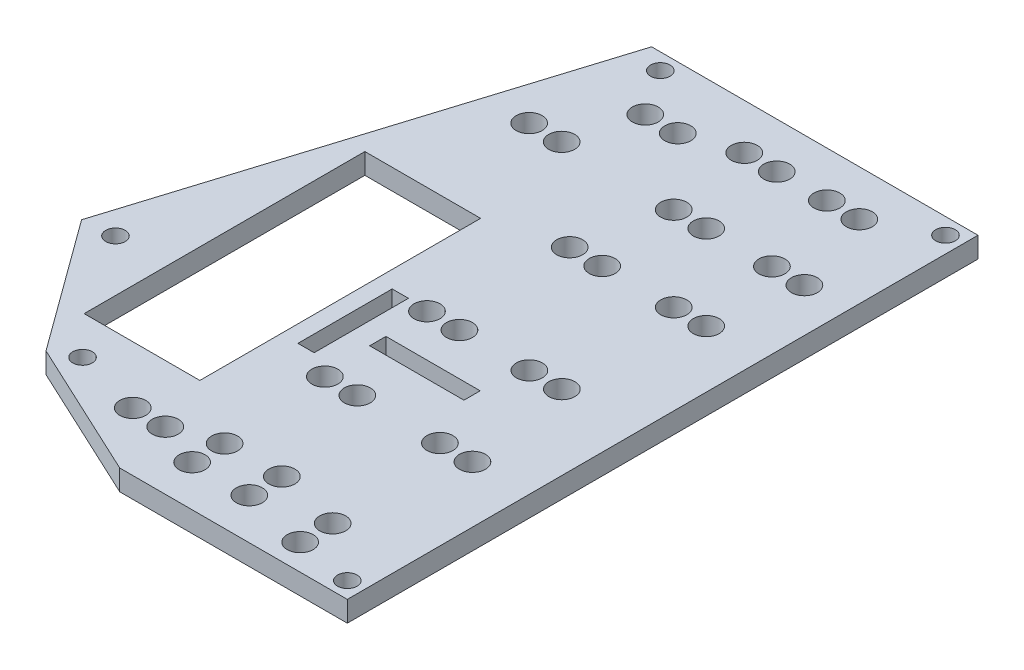
from build123d import *

# Parameters (mm, degrees)
SKETCH1_R           = 1.5
SKETCH1_R_2         = 2
SKETCH1_W           = 2.5
SKETCH1_H           = 14.5
SKETCH1_W_2         = 14.5
SKETCH1_H_2         = 2.5
SKETCH1_W_3         = 17.8
SKETCH1_H_3         = 43.18
BOSS_EXTRUDE1_DEPTH = 3.175


with BuildPart() as part:
    # Sketch1 → Boss-Extrude1 (new body)
    with BuildSketch(Plane(origin=(0, 0, 0), x_dir=(1, 0, 0), z_dir=(0, 1, 0))):
        Polygon((-22.047586286, 28.724844999), (28.152410312, 28.724844999), (28.152410312, -68.278843574), (-6.847589688, -68.278843574), (-28.119391264, -58.34898159), (-42.847468938, -38.147899243), align=None)
        with Locations((25.652410312, 26.224844999)):
            Circle(SKETCH1_R, mode=Mode.SUBTRACT)
        with Locations((25.652410312, -65.778843574)):
            Circle(SKETCH1_R, mode=Mode.SUBTRACT)
        with Locations((-38.087063045, -37.694179546)):
            Circle(SKETCH1_R, mode=Mode.SUBTRACT)
        with Locations((-18.207043121, 26.221156426)):
            Circle(SKETCH1_R, mode=Mode.SUBTRACT)
        with Locations((-24.448175277, -56.401325246)):
            Circle(SKETCH1_R, mode=Mode.SUBTRACT)
        with Locations((16.902410312, 21.724844999)):
            Circle(SKETCH1_R_2, mode=Mode.SUBTRACT)
        with Locations((11.902410312, 21.724844999)):
            Circle(SKETCH1_R_2, mode=Mode.SUBTRACT)
        with Locations((4.202410312, 21.724844999)):
            Circle(SKETCH1_R_2, mode=Mode.SUBTRACT)
        with Locations((-0.797589688, 21.724844999)):
            Circle(SKETCH1_R_2, mode=Mode.SUBTRACT)
        with Locations((-8.518099948, 19.221156426)):
            Circle(SKETCH1_R_2, mode=Mode.SUBTRACT)
        with Locations((-13.518099948, 19.221156426)):
            Circle(SKETCH1_R_2, mode=Mode.SUBTRACT)
        with Locations((-16.301455712, 9.146912193)):
            Circle(SKETCH1_R_2, mode=Mode.SUBTRACT)
        with Locations((-21.301455712, 9.146912193)):
            Circle(SKETCH1_R_2, mode=Mode.SUBTRACT)
        with Locations((-2.047589688, -61.948843574)):
            Circle(SKETCH1_R_2, mode=Mode.SUBTRACT)
        with Locations((-2.047589688, -56.948843574)):
            Circle(SKETCH1_R_2, mode=Mode.SUBTRACT)
        with Locations((6.752410312, -61.948843574)):
            Circle(SKETCH1_R_2, mode=Mode.SUBTRACT)
        with Locations((6.752410312, -56.948843574)):
            Circle(SKETCH1_R_2, mode=Mode.SUBTRACT)
        with Locations((-8.847589688, -59.278843574)):
            Circle(SKETCH1_R_2, mode=Mode.SUBTRACT)
        with Locations((-13.847589688, -59.278843574)):
            Circle(SKETCH1_R_2, mode=Mode.SUBTRACT)
        with Locations((21.452410312, 8.724844999)):
            Circle(SKETCH1_R_2, mode=Mode.SUBTRACT)
        with Locations((16.452410312, 8.724844999)):
            Circle(SKETCH1_R_2, mode=Mode.SUBTRACT)
        with Locations((6.352410312, 8.724844999)):
            Circle(SKETCH1_R_2, mode=Mode.SUBTRACT)
        with Locations((1.352410312, 8.724844999)):
            Circle(SKETCH1_R_2, mode=Mode.SUBTRACT)
        with Locations((14.352410312, -4.275155001)):
            Circle(SKETCH1_R_2, mode=Mode.SUBTRACT)
        with Locations((19.352410312, -4.275155001)):
            Circle(SKETCH1_R_2, mode=Mode.SUBTRACT)
        with Locations((3.352410312, -4.275155001)):
            Circle(SKETCH1_R_2, mode=Mode.SUBTRACT)
        with Locations((-1.647589688, -4.275155001)):
            Circle(SKETCH1_R_2, mode=Mode.SUBTRACT)
        with Locations((16.652410312, -23.778843574)):
            Circle(SKETCH1_R_2, mode=Mode.SUBTRACT)
        with Locations((11.652410312, -23.778843574)):
            Circle(SKETCH1_R_2, mode=Mode.SUBTRACT)
        with Locations((0.902410312, -23.778843574)):
            Circle(SKETCH1_R_2, mode=Mode.SUBTRACT)
        with Locations((-4.097589688, -23.778843574)):
            Circle(SKETCH1_R_2, mode=Mode.SUBTRACT)
        with Locations((19.452410312, -40.334046802)):
            Circle(SKETCH1_R_2, mode=Mode.SUBTRACT)
        with Locations((14.452410312, -40.334046802)):
            Circle(SKETCH1_R_2, mode=Mode.SUBTRACT)
        with Locations((1.752410312, -40.334046802)):
            Circle(SKETCH1_R_2, mode=Mode.SUBTRACT)
        with Locations((-3.247589688, -40.334046802)):
            Circle(SKETCH1_R_2, mode=Mode.SUBTRACT)
        with Locations((16.902410312, -59.278843574)):
            Circle(SKETCH1_R_2, mode=Mode.SUBTRACT)
        with Locations((16.902410312, -64.278843574)):
            Circle(SKETCH1_R_2, mode=Mode.SUBTRACT)
        with Locations((-8.497589688, -30.725155001)):
            Rectangle(SKETCH1_W, SKETCH1_H, mode=Mode.SUBTRACT)
        with Locations((3.342410312, -31.528843574)):
            Rectangle(SKETCH1_W_2, SKETCH1_H_2, mode=Mode.SUBTRACT)
        with Locations((-21.247589688, -28.865155001)):
            Rectangle(SKETCH1_W_3, SKETCH1_H_3, mode=Mode.SUBTRACT)
    extrude(amount=BOSS_EXTRUDE1_DEPTH)


solid = part.part
